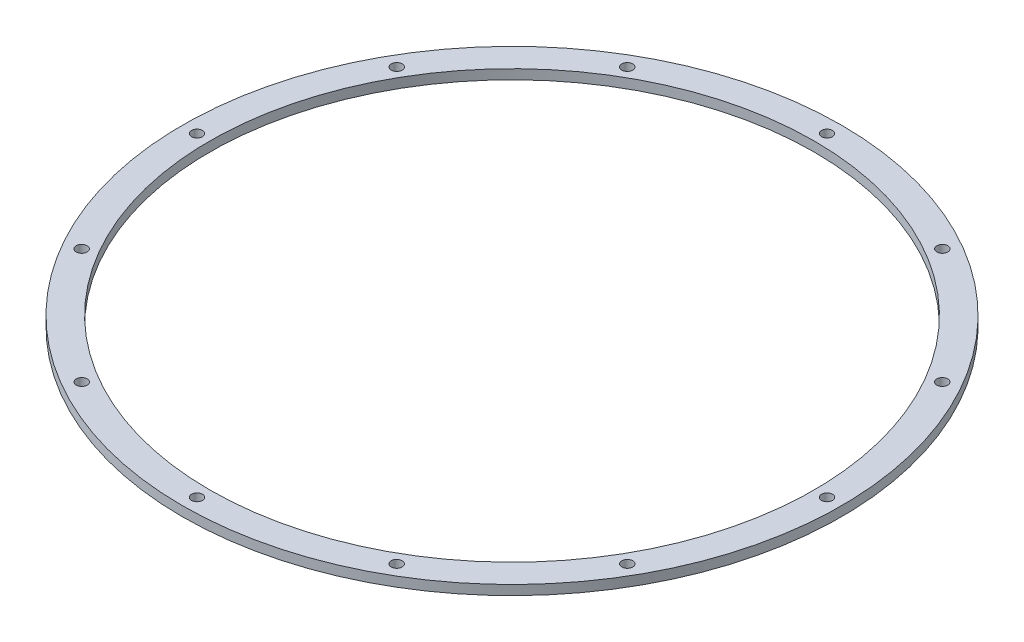
from build123d import *

# Parameters (mm, degrees)
SKETCH1_R           = 102.5
SKETCH1_R_2         = 94
SKETCH1_R_3         = 1.7
BOSS_EXTRUDE1_DEPTH = 3


with BuildPart() as part:
    # Sketch1 → Boss-Extrude1 (new body)
    with BuildSketch(Plane(origin=(0, 0, 0), x_dir=(1, 0, 0), z_dir=(0, 1, 0))):
        Circle(SKETCH1_R)
        Circle(SKETCH1_R_2, mode=Mode.SUBTRACT)
        with Locations((0, 97.974)):
            Circle(SKETCH1_R_3, mode=Mode.SUBTRACT)
        with Locations((48.987, 84.84797291)):
            Circle(SKETCH1_R_3, mode=Mode.SUBTRACT)
        with Locations((84.84797291, 48.987)):
            Circle(SKETCH1_R_3, mode=Mode.SUBTRACT)
        with Locations((97.974, 0)):
            Circle(SKETCH1_R_3, mode=Mode.SUBTRACT)
        with Locations((84.84797291, -48.987)):
            Circle(SKETCH1_R_3, mode=Mode.SUBTRACT)
        with Locations((48.987, -84.84797291)):
            Circle(SKETCH1_R_3, mode=Mode.SUBTRACT)
        with Locations((0, -97.974)):
            Circle(SKETCH1_R_3, mode=Mode.SUBTRACT)
        with Locations((-48.987, -84.84797291)):
            Circle(SKETCH1_R_3, mode=Mode.SUBTRACT)
        with Locations((-84.84797291, -48.987)):
            Circle(SKETCH1_R_3, mode=Mode.SUBTRACT)
        with Locations((-97.974, 0)):
            Circle(SKETCH1_R_3, mode=Mode.SUBTRACT)
        with Locations((-84.84797291, 48.987)):
            Circle(SKETCH1_R_3, mode=Mode.SUBTRACT)
        with Locations((-48.987, 84.84797291)):
            Circle(SKETCH1_R_3, mode=Mode.SUBTRACT)
    extrude(amount=BOSS_EXTRUDE1_DEPTH)


solid = part.part
